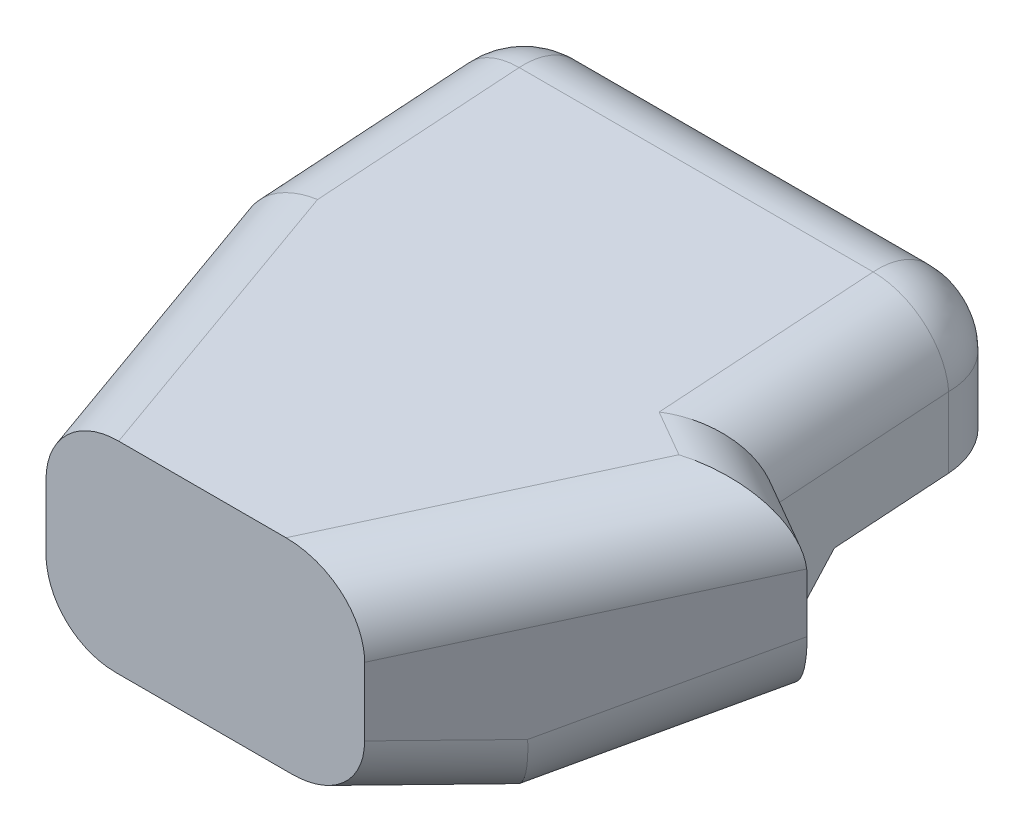
from build123d import *

# Parameters (mm, degrees)
EXTRUDE1_DEPTH     = 48.26
SKETCH3_OUTSIDE_W  = 133.914
SKETCH3_OUTSIDE_H  = 80.574
CUT_EXTRUDE1_DEPTH = 127
FILLET1_R          = 12.7
FILLET2_R          = 12.7


with BuildPart() as part:
    # Sketch1 → Extrude1 (new body)
    with BuildSketch(Plane(origin=(0, 0, 0), x_dir=(1, 0, 0), z_dir=(0, 1, 0))):
        Polygon((-44.45, 101.6), (44.45, 101.6), (44.45, 57.94375), (57.15, 50.8), (28.575, 0), (-28.575, 0), (-44.45, 50.8), align=None)
    extrude(amount=EXTRUDE1_DEPTH)

    # Sketch3 outside → Cut-Extrude1 (cut, symmetric)
    with BuildSketch(Plane.ZY.offset(44.45)):
        with Locations((-50.8, 24.13)):
            Rectangle(SKETCH3_OUTSIDE_W, SKETCH3_OUTSIDE_H)
        Polygon((0, 41.445288221), (-101.6, 48.26), (-101.6, 22.86), (-68.397585835, 20.632983436), (-57.94375, 9.084619968), (-25.4, 0), (0, 5.240594668), align=None, mode=Mode.SUBTRACT)
    extrude(amount=CUT_EXTRUDE1_DEPTH, both=True, mode=Mode.SUBTRACT)

    # Fillet1
    fillet1_edges = [part.edges().sort_by_distance(p)[0] for p in [
        (-44.45, 35.56, -101.6),
        (-44.45, 46.556322055, -76.2),
        (42.8625, 43.148966165, -25.4),
        (0, 48.26, -101.6),
        (50.8, 45.092223821, -54.371875),
        (44.45, 35.56, -101.6),
        (44.45, 46.795901766, -79.771875),
        (-36.5125, 43.148966165, -25.4),
    ]]
    fillet(fillet1_edges, radius=FILLET1_R)

    # Fillet2
    fillet2_edges = [part.edges().sort_by_distance(p)[0] for p in [
        (-40.48125, 3.545217548, -38.1),
        (-32.54375, 2.620297334, -12.7),
        (50.00625, 3.545217548, -38.1),
        (35.71875, 2.620297334, -12.7),
    ]]
    fillet(fillet2_edges, radius=FILLET2_R)


solid = part.part
